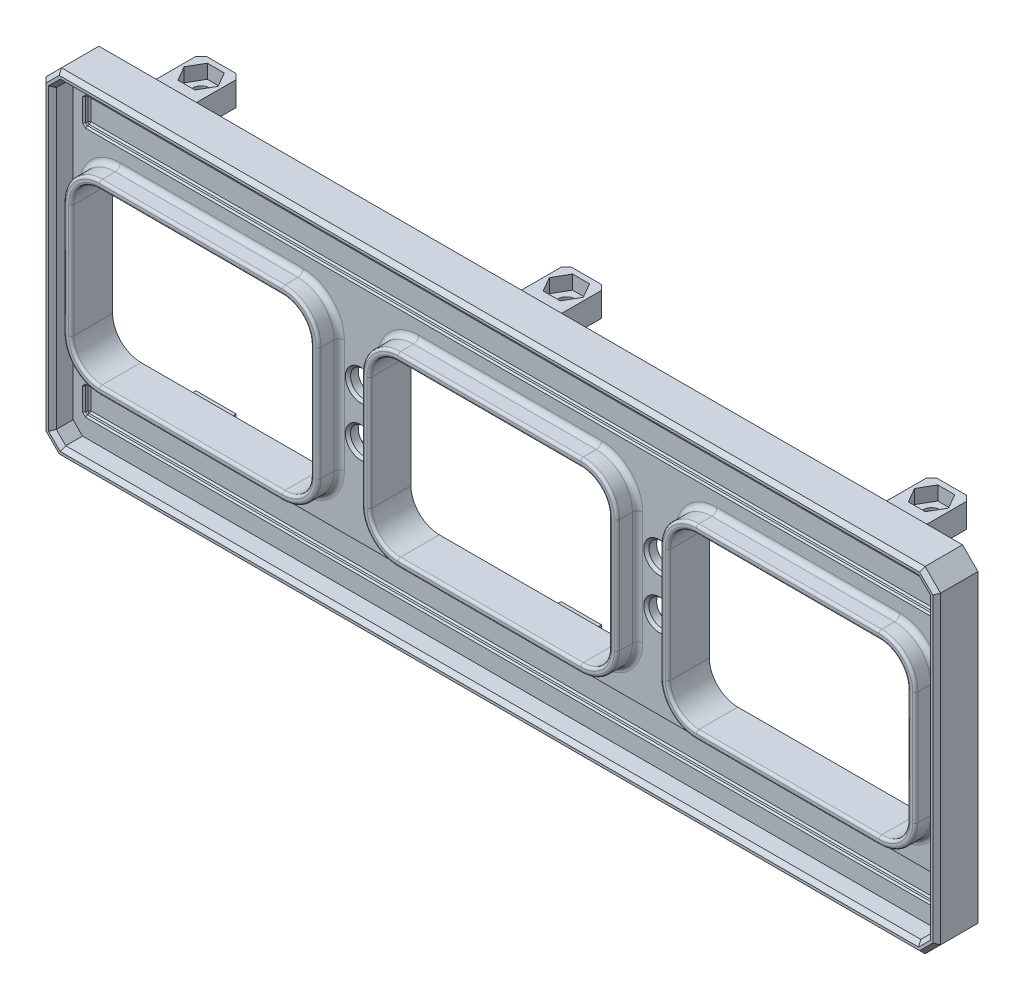
from build123d import *

# Parameters (mm, degrees)
SKETCH1_W           = 173.3
SKETCH1_H           = 65
SKETCH1_W_2         = 46.4
SKETCH1_H_2         = 33
BOSS_EXTRUDE1_DEPTH = 4
SKETCH2_W           = 7.8
SKETCH2_H           = 10.8
BOSS_EXTRUDE2_DEPTH = 4.7
SKETCH3_W           = 7.8
SKETCH3_H           = 10.8
BOSS_EXTRUDE3_DEPTH = 4.7
CUT_EXTRUDE1_DEPTH  = 2.7
SKETCH5_R           = 1.6
CUT_EXTRUDE2_DEPTH  = 2
CUT_EXTRUDE3_DEPTH  = 2.7
SKETCH7_R           = 1.6
CUT_EXTRUDE4_DEPTH  = 2
SKETCH8_R           = 2.5
CUT_EXTRUDE5_DEPTH  = 4
CUT_EXTRUDE8_DEPTH  = 2
CHAMFER1_SIZE       = 1
SKETCH9_W           = 173.3
SKETCH9_H           = 65
SKETCH9_W_2         = 169.3
SKETCH9_H_2         = 61
SKETCH9_W_3         = 49.4
SKETCH9_H_3         = 36
SKETCH9_W_4         = 46.4
SKETCH9_H_4         = 33
BOSS_EXTRUDE4_DEPTH = 4
SKETCH11_W          = 165
SKETCH11_H          = 5
CUT_EXTRUDE6_DEPTH  = 1
SKETCH15_R          = 2.85
CUT_EXTRUDE7_DEPTH  = 2.5
CHAMFER3_SIZE       = 3
CHAMFER5_SIZE       = 1.828427125
CHAMFER6_SIZE       = 0.75
CHAMFER8_SIZE       = 0.3
CHAMFER9_SIZE       = 0.5
FILLET3_R           = 5.5
FILLET4_R           = 7
FILLET5_R           = 1
FILLET6_R           = 0.5


with BuildPart() as part:
    # Sketch1 → Boss-Extrude1 (new body)
    with BuildSketch(Plane.XY):
        with Locations((-37.310621762, 18.15036632)):
            Rectangle(SKETCH1_W, SKETCH1_H)
        with Locations((-37.310621762, 18.15036632)):
            Rectangle(SKETCH1_W_2, SKETCH1_H_2, mode=Mode.SUBTRACT)
        with Locations((-95.110621762, 18.15036632)):
            Rectangle(SKETCH1_W_2, SKETCH1_H_2, mode=Mode.SUBTRACT)
        with Locations((20.489378238, 18.15036632)):
            Rectangle(SKETCH1_W_2, SKETCH1_H_2, mode=Mode.SUBTRACT)
    extrude(amount=BOSS_EXTRUDE1_DEPTH)

    # Sketch2 → Boss-Extrude2 (add)
    with BuildSketch(Plane(origin=(0, 48.55036632, 0), x_dir=(1, 0, 0), z_dir=(0, 1, 0))):
        with Locations((-37.310621762, 5.4)):
            Rectangle(SKETCH2_W, SKETCH2_H)
        with Locations((33.439378238, 5.4)):
            Rectangle(SKETCH2_W, SKETCH2_H)
        with Locations((-108.060621762, 5.4)):
            Rectangle(SKETCH2_W, SKETCH2_H)
    extrude(amount=-BOSS_EXTRUDE2_DEPTH)

    # Sketch3 → Boss-Extrude3 (add)
    with BuildSketch(Plane(origin=(0, -12.24963368, 0), x_dir=(-1, 0, 0), z_dir=(0, -1, 0))):
        with Locations((37.310621762, 5.4)):
            Rectangle(SKETCH3_W, SKETCH3_H)
        with Locations((108.060621762, 5.4)):
            Rectangle(SKETCH3_W, SKETCH3_H)
        with Locations((-33.439378238, 5.4)):
            Rectangle(SKETCH3_W, SKETCH3_H)
    extrude(amount=-BOSS_EXTRUDE3_DEPTH)

    # Sketch4 → Cut-Extrude1 (cut)
    with BuildSketch(Plane(origin=(0, 48.55036632, 0), x_dir=(1, 0, 0), z_dir=(0, 1, 0))):
        Polygon((-34.019725227, 6.9), (-35.665173494, 9.75), (-38.956070029, 9.75), (-40.601518296, 6.9), (-38.956070029, 4.05), (-35.665173494, 4.05), align=None)
        Polygon((36.730274773, 6.9), (35.084826506, 9.75), (31.793929971, 9.75), (30.148481704, 6.9), (31.793929971, 4.05), (35.084826506, 4.05), align=None)
        Polygon((-104.769725227, 6.9), (-106.415173494, 9.75), (-109.706070029, 9.75), (-111.351518296, 6.9), (-109.706070029, 4.05), (-106.415173494, 4.05), align=None)
    extrude(amount=-CUT_EXTRUDE1_DEPTH, mode=Mode.SUBTRACT)

    # Sketch5 → Cut-Extrude2 (cut)
    with BuildSketch(Plane(origin=(0, 45.85036632, 0), x_dir=(1, 0, 0), z_dir=(0, 1, 0))):
        with Locations(Location((-37.310621762, 6.9, 0), (0, 0, 270))):
            Circle(SKETCH5_R)
        with Locations(Location((-108.060621762, 6.9, 0), (0, 0, 270))):
            Circle(SKETCH5_R)
        with Locations(Location((33.439378238, 6.9, 0), (0, 0, 270))):
            Circle(SKETCH5_R)
    extrude(amount=-CUT_EXTRUDE2_DEPTH, mode=Mode.SUBTRACT)

    # Sketch6 → Cut-Extrude3 (cut)
    with BuildSketch(Plane.XZ.offset(12.24963368)):
        Polygon((-34.019725227, -6.9), (-35.665173494, -4.05), (-38.956070029, -4.05), (-40.601518296, -6.9), (-38.956070029, -9.75), (-35.665173494, -9.75), align=None)
        Polygon((36.730274773, -6.9), (35.084826506, -4.05), (31.793929971, -4.05), (30.148481704, -6.9), (31.793929971, -9.75), (35.084826506, -9.75), align=None)
        Polygon((-104.769725227, -6.9), (-106.415173494, -4.05), (-109.706070029, -4.05), (-111.351518296, -6.9), (-109.706070029, -9.75), (-106.415173494, -9.75), align=None)
    extrude(amount=-CUT_EXTRUDE3_DEPTH, mode=Mode.SUBTRACT)

    # Sketch7 → Cut-Extrude4 (cut)
    with BuildSketch(Plane.XZ.offset(9.54963368)):
        with Locations(Location((-37.310621762, -6.9, 0), (0, 0, 90))):
            Circle(SKETCH7_R)
        with Locations(Location((33.439378238, -6.9, 0), (0, 0, 90))):
            Circle(SKETCH7_R)
        with Locations(Location((-108.060621762, -6.9, 0), (0, 0, 90))):
            Circle(SKETCH7_R)
    extrude(amount=-CUT_EXTRUDE4_DEPTH, mode=Mode.SUBTRACT)

    # Sketch8 → Cut-Extrude5 (cut)
    with BuildSketch(Plane.XY.offset(4)):
        with Locations((-66.210621762, 23.15036632)):
            Circle(SKETCH8_R)
        with Locations((-66.210621762, 13.55036632)):
            Circle(SKETCH8_R)
        with Locations((-8.410621762, 23.15036632)):
            Circle(SKETCH8_R)
        with Locations((-8.410621762, 13.55036632)):
            Circle(SKETCH8_R)
    extrude(amount=-CUT_EXTRUDE5_DEPTH, mode=Mode.SUBTRACT)

    # Sketch17 → Cut-Extrude8 (cut)
    with BuildSketch(Plane(origin=(0, 0, 0), x_dir=(-1, 0, 0), z_dir=(0, 0, -1))):
        with BuildLine():
            Line((4.910621762, 9.85036632), (11.910621762, 9.85036632))
            ThreePointArc((11.910621762, 9.85036632), (12.617728543, 10.143259539), (12.910621762, 10.85036632))
            Line((12.910621762, 10.85036632), (12.910621762, 25.85036632))
            ThreePointArc((12.910621762, 25.85036632), (12.617728543, 26.557473101), (11.910621762, 26.85036632))
            Line((11.910621762, 26.85036632), (4.910621762, 26.85036632))
            ThreePointArc((4.910621762, 26.85036632), (4.20351498, 26.557473101), (3.910621762, 25.85036632))
            Line((3.910621762, 25.85036632), (3.910621762, 10.85036632))
            ThreePointArc((3.910621762, 10.85036632), (4.20351498, 10.143259539), (4.910621762, 9.85036632))
        make_face()
        with BuildLine():
            Line((69.710621762, 26.85036632), (62.710621762, 26.85036632))
            ThreePointArc((62.710621762, 26.85036632), (62.00351498, 26.557473101), (61.710621762, 25.85036632))
            Line((61.710621762, 25.85036632), (61.710621762, 10.85036632))
            ThreePointArc((61.710621762, 10.85036632), (62.00351498, 10.143259539), (62.710621762, 9.85036632))
            Line((62.710621762, 9.85036632), (69.710621762, 9.85036632))
            ThreePointArc((69.710621762, 9.85036632), (70.417728543, 10.143259539), (70.710621762, 10.85036632))
            Line((70.710621762, 10.85036632), (70.710621762, 25.85036632))
            ThreePointArc((70.710621762, 25.85036632), (70.417728543, 26.557473101), (69.710621762, 26.85036632))
        make_face()
    extrude(amount=-CUT_EXTRUDE8_DEPTH, mode=Mode.SUBTRACT)

    # Chamfer1
    chamfer1_edges = [part.edges().sort_by_distance(p)[0] for p in [
        (-108.060621762, -7.54963368, -10.8),
        (-104.160621762, -9.89963368, -10.8),
        (-111.960621762, -9.89963368, -10.8),
        (33.439378238, -7.54963368, -10.8),
        (37.339378238, -9.89963368, -10.8),
        (29.539378238, -9.89963368, -10.8),
        (-37.310621762, 43.85036632, -10.8),
        (-41.210621762, 46.20036632, -10.8),
        (-33.410621762, 46.20036632, -10.8),
        (33.439378238, 43.85036632, -10.8),
        (29.539378238, 46.20036632, -10.8),
        (37.339378238, 46.20036632, -10.8),
        (-104.160621762, 46.20036632, -10.8),
        (-108.060621762, 43.85036632, -10.8),
        (-111.960621762, 46.20036632, -10.8),
        (-41.210621762, -9.89963368, -10.8),
        (-37.310621762, -7.54963368, -10.8),
        (-33.410621762, -9.89963368, -10.8),
    ]]
    chamfer(chamfer1_edges, length=CHAMFER1_SIZE)

    # Sketch9 → Boss-Extrude4 (add)
    with BuildSketch(Plane.XY.offset(4)):
        with Locations((-37.310621762, 18.15036632)):
            Rectangle(SKETCH9_W, SKETCH9_H)
        with Locations((-37.310621762, 18.15036632)):
            Rectangle(SKETCH9_W_2, SKETCH9_H_2, mode=Mode.SUBTRACT)
        with Locations((20.489378238, 18.15036632)):
            Rectangle(SKETCH9_W_3, SKETCH9_H_3)
        with Locations((20.489378238, 18.15036632)):
            Rectangle(SKETCH9_W_4, SKETCH9_H_4, mode=Mode.SUBTRACT)
        with Locations((-37.310621762, 18.15036632)):
            Rectangle(SKETCH9_W_3, SKETCH9_H_3)
        with Locations((-37.310621762, 18.15036632)):
            Rectangle(SKETCH9_W_4, SKETCH9_H_4, mode=Mode.SUBTRACT)
        with Locations((-95.110621762, 18.15036632)):
            Rectangle(SKETCH9_W_3, SKETCH9_H_3)
        with Locations((-95.110621762, 18.15036632)):
            Rectangle(SKETCH9_W_4, SKETCH9_H_4, mode=Mode.SUBTRACT)
    extrude(amount=BOSS_EXTRUDE4_DEPTH)

    # Sketch11 → Cut-Extrude6 (cut)
    with BuildSketch(Plane.XY.offset(4)):
        with Locations((-37.310621762, 42.40036632)):
            Rectangle(SKETCH11_W, SKETCH11_H)
        with Locations((-37.310621762, -6.09963368)):
            Rectangle(SKETCH11_W, SKETCH11_H)
    extrude(amount=-CUT_EXTRUDE6_DEPTH, mode=Mode.SUBTRACT)

    # Sketch15 → Cut-Extrude7 (cut)
    with BuildSketch(Plane(origin=(0, 0, 0), x_dir=(-1, 0, 0), z_dir=(0, 0, -1))):
        with Locations((8.410621762, 30.15036632)):
            Circle(SKETCH15_R)
        with Locations((8.410621762, 6.15036632)):
            Circle(SKETCH15_R)
        with Locations((66.210621762, 30.15036632)):
            Circle(SKETCH15_R)
        with Locations((66.210621762, 6.15036632)):
            Circle(SKETCH15_R)
    extrude(amount=-CUT_EXTRUDE7_DEPTH, mode=Mode.SUBTRACT)

    # Chamfer3
    chamfer3_edges = [part.edges().sort_by_distance(p)[0] for p in [
        (-123.960621762, 50.65036632, 4),
        (49.339378238, 50.65036632, 4),
        (49.339378238, -14.34963368, 4),
        (-123.960621762, -14.34963368, 4),
    ]]
    chamfer(chamfer3_edges, length=CHAMFER3_SIZE)

    # Chamfer5
    chamfer5_edges = [part.edges().sort_by_distance(p)[0] for p in [
        (-121.960621762, -12.34963368, 6),
        (-121.960621762, 48.65036632, 6),
        (47.339378238, 48.65036632, 6),
        (47.339378238, -12.34963368, 6),
    ]]
    chamfer(chamfer5_edges, length=CHAMFER5_SIZE)

    # Chamfer6
    chamfer6_edges = [part.edges().sort_by_distance(p)[0] for p in [
        (49.339378238, 18.15036632, 8),
        (-37.310621762, -14.34963368, 8),
        (-37.310621762, 50.65036632, 8),
        (-123.960621762, 18.15036632, 8),
        (-122.460621762, -12.84963368, 8),
        (-122.460621762, 49.15036632, 8),
        (47.839378238, 49.15036632, 8),
        (47.839378238, -12.84963368, 8),
        (-37.310621762, -12.34963368, 8),
        (47.339378238, 18.15036632, 8),
        (-37.310621762, 48.65036632, 8),
        (-121.960621762, 18.15036632, 8),
        (46.425164676, -11.435420118, 8),
        (46.425164676, 47.736152757, 8),
        (-121.046408199, 47.736152757, 8),
        (-121.046408199, -11.435420118, 8),
    ]]
    chamfer(chamfer6_edges, length=CHAMFER6_SIZE)

    # Chamfer8
    chamfer8_edges = [part.edges().sort_by_distance(p)[0] for p in [
        (-119.810621762, 42.40036632, 3),
        (-119.810621762, 39.90036632, 3.5),
        (-37.310621762, 44.90036632, 3),
        (-119.810621762, 44.90036632, 3.5),
        (45.189378238, 42.40036632, 3),
        (45.189378238, 44.90036632, 3.5),
        (-37.310621762, 39.90036632, 3),
        (45.189378238, 39.90036632, 3.5),
        (-119.810621762, 42.40036632, 4),
        (-37.310621762, 39.90036632, 4),
        (45.189378238, 42.40036632, 4),
        (-37.310621762, 44.90036632, 4),
        (45.189378238, -6.09963368, 3),
        (45.189378238, -3.59963368, 3.5),
        (-37.310621762, -8.59963368, 3),
        (45.189378238, -8.59963368, 3.5),
        (-119.810621762, -6.09963368, 3),
        (-119.810621762, -8.59963368, 3.5),
        (-37.310621762, -3.59963368, 3),
        (-119.810621762, -3.59963368, 3.5),
        (45.189378238, -6.09963368, 4),
        (-37.310621762, -3.59963368, 4),
        (-119.810621762, -6.09963368, 4),
        (-37.310621762, -8.59963368, 4),
    ]]
    chamfer(chamfer8_edges, length=CHAMFER8_SIZE)

    # Chamfer9
    chamfer9_edges = [part.edges().sort_by_distance(p)[0] for p in [
        (-68.710621762, 13.55036632, 4),
        (-10.910621762, 23.15036632, 4),
        (-10.910621762, 13.55036632, 4),
        (-68.710621762, 23.15036632, 4),
    ]]
    chamfer(chamfer9_edges, length=CHAMFER9_SIZE)

    # Fillet3
    fillet3_edges = [part.edges().sort_by_distance(p)[0] for p in [
        (-118.310621762, 34.65036632, 4),
        (-118.310621762, 1.65036632, 4),
        (-71.910621762, 1.65036632, 4),
        (-71.910621762, 34.65036632, 4),
        (-2.710621762, 1.65036632, 4),
        (43.689378238, 1.65036632, 4),
        (43.689378238, 34.65036632, 4),
        (-2.710621762, 34.65036632, 4),
        (-60.510621762, 34.65036632, 4),
        (-60.510621762, 1.65036632, 4),
        (-14.110621762, 1.65036632, 4),
        (-14.110621762, 34.65036632, 4),
    ]]
    fillet(fillet3_edges, radius=FILLET3_R)

    # Fillet4
    fillet4_edges = [part.edges().sort_by_distance(p)[0] for p in [
        (-70.410621762, 0.15036632, 6),
        (-70.410621762, 36.15036632, 6),
        (-119.810621762, 36.15036632, 6),
        (-119.810621762, 0.15036632, 6),
        (-62.010621762, 36.15036632, 6),
        (-62.010621762, 0.15036632, 6),
        (-12.610621762, 0.15036632, 6),
        (-12.610621762, 36.15036632, 6),
        (-4.210621762, 36.15036632, 6),
        (-4.210621762, 0.15036632, 6),
        (45.189378238, 0.15036632, 6),
        (45.189378238, 36.15036632, 6),
    ]]
    fillet(fillet4_edges, radius=FILLET4_R)

    # Fillet5
    fillet5_edges = [part.edges().sort_by_distance(p)[0] for p in [
        (45.189378238, 18.15036632, 4),
        (20.489378238, 0.15036632, 4),
        (20.489378238, 36.15036632, 4),
        (-37.310621762, 36.15036632, 4),
        (-12.610621762, 18.15036632, 4),
        (-62.010621762, 18.15036632, 4),
        (-4.210621762, 18.15036632, 4),
        (-37.310621762, 0.15036632, 4),
        (-95.110621762, 0.15036632, 4),
        (-119.810621762, 18.15036632, 4),
        (-95.110621762, 36.15036632, 4),
        (-70.410621762, 18.15036632, 4),
        (43.139125707, 2.200618851, 4),
        (43.139125707, 34.100113788, 4),
        (-14.660874293, 34.100113788, 4),
        (-59.96036923, 34.100113788, 4),
        (-2.16036923, 34.100113788, 4),
        (-2.16036923, 2.200618851, 4),
        (-14.660874293, 2.200618851, 4),
        (-59.96036923, 2.200618851, 4),
        (-117.76036923, 2.200618851, 4),
        (-117.76036923, 34.100113788, 4),
        (-72.460874293, 34.100113788, 4),
        (-72.460874293, 2.200618851, 4),
    ]]
    fillet(fillet5_edges, radius=FILLET5_R)

    # Fillet6
    fillet6_edges = [part.edges().sort_by_distance(p)[0] for p in [
        (-37.310621762, 1.65036632, 8),
        (-14.110621762, 18.15036632, 8),
        (20.489378238, 1.65036632, 8),
        (43.689378238, 18.15036632, 8),
        (-2.710621762, 18.15036632, 8),
        (-60.510621762, 18.15036632, 8),
        (-37.310621762, 34.65036632, 8),
        (20.489378238, 34.65036632, 8),
        (-118.310621762, 18.15036632, 8),
        (-95.110621762, 1.65036632, 8),
        (-71.910621762, 18.15036632, 8),
        (-95.110621762, 34.65036632, 8),
        (-15.721534465, 3.261279023, 8),
        (42.078465535, 3.261279023, 8),
        (-1.099709058, 3.261279023, 8),
        (-58.899709058, 3.261279023, 8),
        (-58.899709058, 33.039453616, 8),
        (-1.099709058, 33.039453616, 8),
        (42.078465535, 33.039453616, 8),
        (-15.721534465, 33.039453616, 8),
        (-116.699709058, 3.261279023, 8),
        (-73.521534465, 3.261279023, 8),
        (-73.521534465, 33.039453616, 8),
        (-116.699709058, 33.039453616, 8),
        (45.189378238, 18.15036632, 8),
        (20.489378238, 0.15036632, 8),
        (-4.210621762, 18.15036632, 8),
        (20.489378238, 36.15036632, 8),
        (-2.16036923, 2.200618851, 8),
        (-2.16036923, 34.100113788, 8),
        (43.139125707, 34.100113788, 8),
        (43.139125707, 2.200618851, 8),
        (-37.310621762, 36.15036632, 8),
        (-12.610621762, 18.15036632, 8),
        (-62.010621762, 18.15036632, 8),
        (-37.310621762, 0.15036632, 8),
        (-59.96036923, 2.200618851, 8),
        (-14.660874293, 2.200618851, 8),
        (-59.96036923, 34.100113788, 8),
        (-14.660874293, 34.100113788, 8),
        (-95.110621762, 0.15036632, 8),
        (-119.810621762, 18.15036632, 8),
        (-70.410621762, 18.15036632, 8),
        (-95.110621762, 36.15036632, 8),
        (-72.460874293, 2.200618851, 8),
        (-72.460874293, 34.100113788, 8),
        (-117.76036923, 34.100113788, 8),
        (-117.76036923, 2.200618851, 8),
    ]]
    fillet(fillet6_edges, radius=FILLET6_R)


solid = part.part
